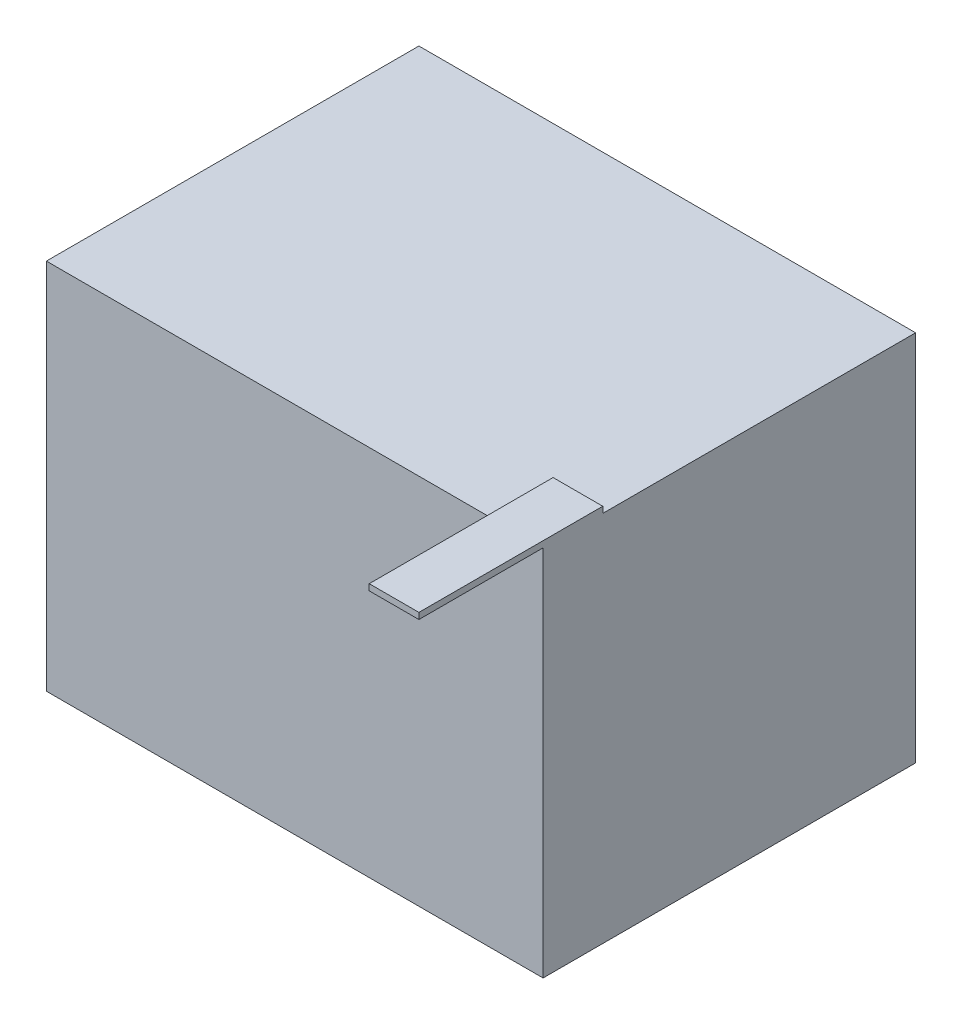
from build123d import *

# Parameters (mm, degrees)
SKETCH1_W           = 800
SKETCH1_H           = 600
BOSS_EXTRUDE1_DEPTH = 600
SKETCH2_W           = 80
SKETCH2_H           = 296.095416522
BOSS_EXTRUDE2_DEPTH = 10


with BuildPart() as part:
    # Sketch1 → Boss-Extrude1 (new body)
    with BuildSketch(Plane(origin=(0, 0, 0), x_dir=(1, 0, 0), z_dir=(0, 1, 0))):
        with Locations((400, 300)):
            Rectangle(SKETCH1_W, SKETCH1_H)
    extrude(amount=BOSS_EXTRUDE1_DEPTH)

    # Sketch2 → Boss-Extrude2 (add)
    with BuildSketch(Plane(origin=(0, 600, 0), x_dir=(1, 0, 0), z_dir=(0, 1, 0))):
        with Locations((760, -51.952291739)):
            Rectangle(SKETCH2_W, SKETCH2_H)
    extrude(amount=BOSS_EXTRUDE2_DEPTH)


solid = part.part
